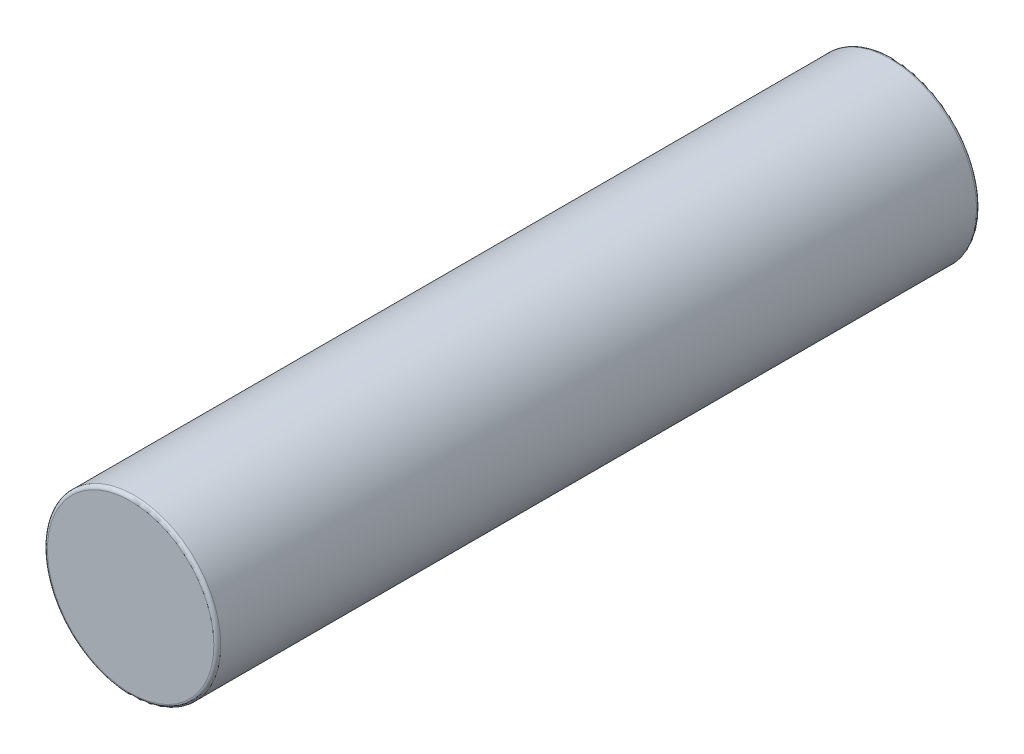
from build123d import *

# Parameters (mm, degrees)
SKETCH1_R           = 1.25
BOSS_EXTRUDE1_DEPTH = 11
FILLET1_R           = 0.05


with BuildPart() as part:
    # Sketch1 → Boss-Extrude1 (new body)
    with BuildSketch(Plane.XY):
        Circle(SKETCH1_R)
    extrude(amount=BOSS_EXTRUDE1_DEPTH)

    # Fillet1
    fillet1_edges = [part.edges().sort_by_distance(p)[0] for p in [
        (-1.25, 0, 0),
        (-1.25, 0, 11),
    ]]
    fillet(fillet1_edges, radius=FILLET1_R)


solid = part.part
